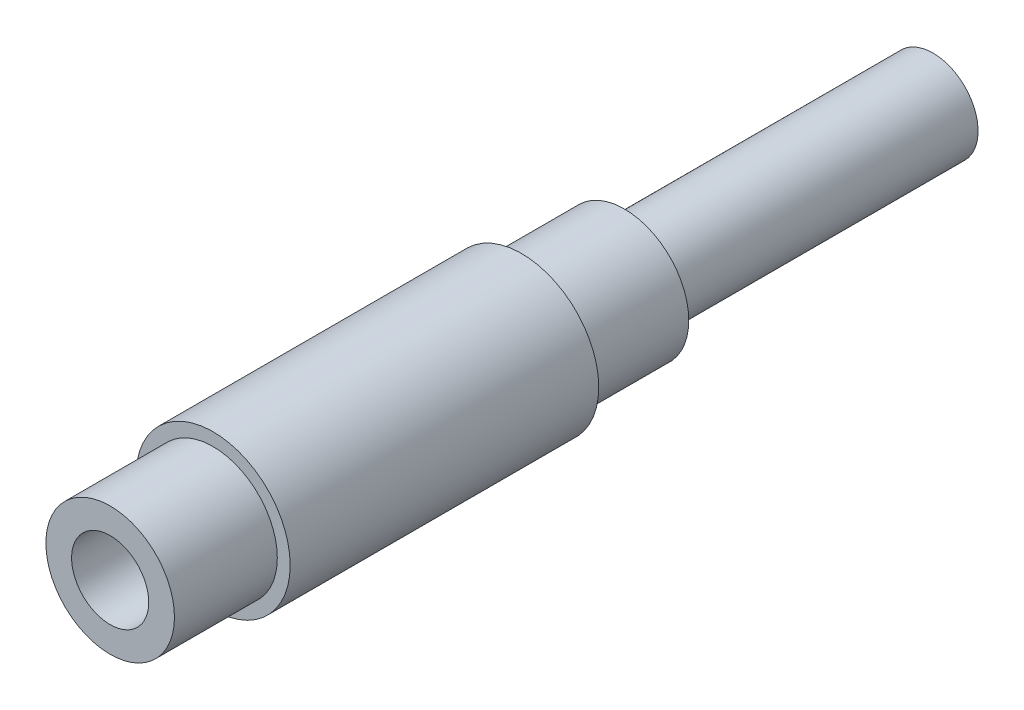
from build123d import *

# Parameters (mm, degrees)
SKETCH1_R           = 7.9375
BOSS_EXTRUDE1_DEPTH = 63.5
SKETCH4_R           = 5.5626
BOSS_EXTRUDE2_DEPTH = 38.1
SKETCH6_R           = 9.525
BOSS_EXTRUDE4_DEPTH = 38.1
SKETCH3_R           = 4.7625
CUT_EXTRUDE2_DEPTH  = 38.1


with BuildPart() as part:
    # Sketch1 → Boss-Extrude1 (new body)
    with BuildSketch(Plane.XY):
        Circle(SKETCH1_R)
    extrude(amount=BOSS_EXTRUDE1_DEPTH)

    # Sketch4 → Boss-Extrude2 (add)
    with BuildSketch(Plane(origin=(0, 0, 0), x_dir=(-1, 0, 0), z_dir=(0, 0, -1))):
        Circle(SKETCH4_R)
    extrude(amount=BOSS_EXTRUDE2_DEPTH)

    # Sketch6 → Boss-Extrude4 (add)
    with BuildSketch(Plane.XY.offset(12.7)):
        Circle(SKETCH6_R)
    extrude(amount=BOSS_EXTRUDE4_DEPTH)

    # Sketch3 → Cut-Extrude2 (cut)
    with BuildSketch(Plane.XY.offset(63.5)):
        Circle(SKETCH3_R)
    extrude(amount=-CUT_EXTRUDE2_DEPTH, mode=Mode.SUBTRACT)


solid = part.part
